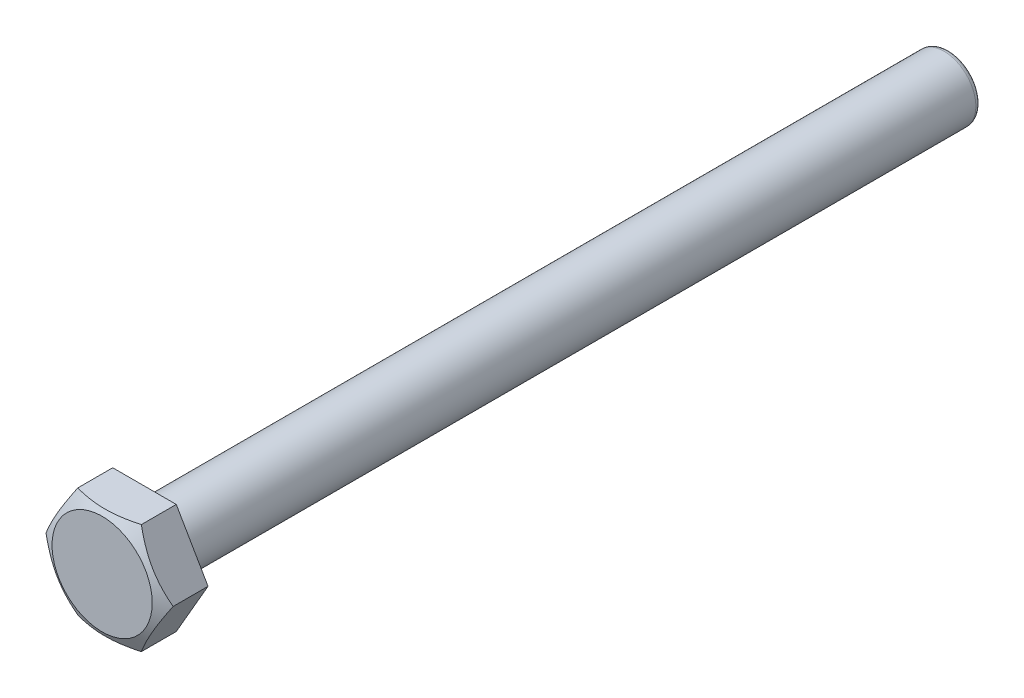
from build123d import *

# Parameters (mm, degrees)
BOSS_EXTRUDE1_DEPTH = 4
SKETCH5_R           = 3
BOSS_EXTRUDE2_DEPTH = 76
FILLET1_R           = 0.5


with BuildPart() as part:
    # Sketch1 → Boss-Extrude1 (new body)
    with BuildSketch(Plane.XY):
        Polygon((6, 0), (3, 5.196152423), (-3, 5.196152423), (-6, 0), (-3, -5.196152423), (3, -5.196152423), align=None)
    extrude(amount=BOSS_EXTRUDE1_DEPTH)

    # Sketch4 → Cut-Revolve1 (revolve, cut)
    with BuildSketch(Plane(origin=(0, 0, 0), x_dir=(0, 0, -1), z_dir=(0.866025404, 0.5, 0))):
        Polygon((-4, 4.729715048), (-3.3, 6), (-4, 6), align=None)
    revolve(axis=Axis((0, 0, 6.225223698), (0, 0, -1)), mode=Mode.SUBTRACT)

    # Sketch5 → Boss-Extrude2 (add)
    with BuildSketch(Plane(origin=(0, 0, 0), x_dir=(-1, 0, 0), z_dir=(0, 0, -1))):
        Circle(SKETCH5_R)
    extrude(amount=BOSS_EXTRUDE2_DEPTH)

    # Fillet1
    fillet1_edges = [part.edges().sort_by_distance(p)[0] for p in [
        (3, 0, -76),
    ]]
    fillet(fillet1_edges, radius=FILLET1_R)


solid = part.part
